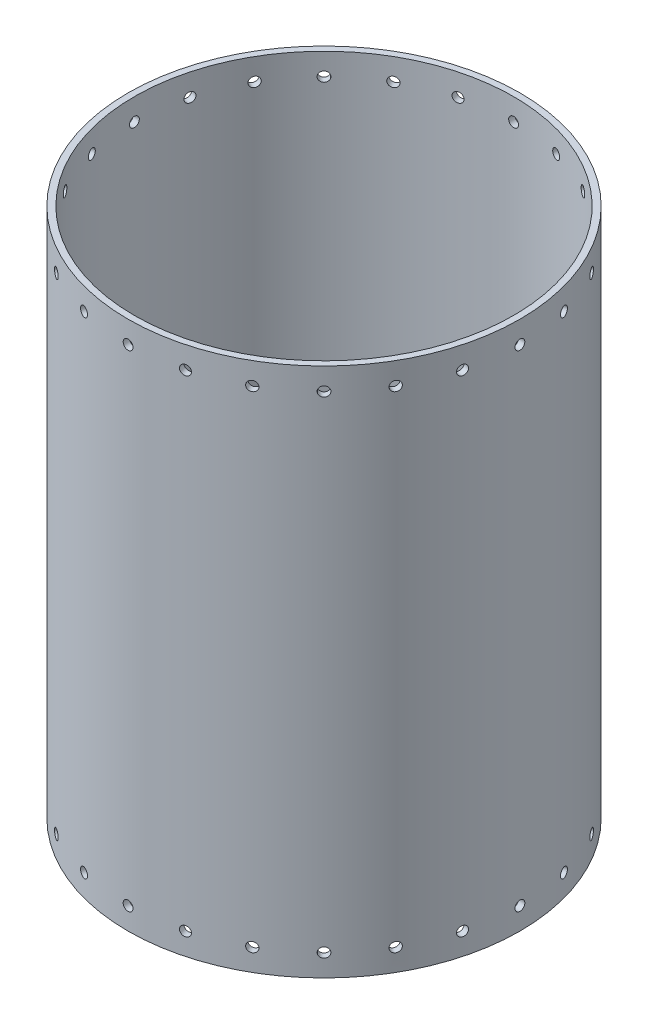
from build123d import *

# Parameters (mm, degrees)
SKETCH1_R                = 101.727
SKETCH1_R_2              = 98.425
EXTRUDE_THIN1_DEPTH      = 275.082
SKETCH2_W                = 2.54
SKETCH2_H                = 12.7
CIRPATTERN1_COUNT        = 24
MIRROR1_COPY_1_SKETCH_W  = 2.54
MIRROR1_COPY_1_SKETCH_H  = 12.7
MIRROR1_COPY_2_SKETCH_W  = 2.54
MIRROR1_COPY_2_SKETCH_H  = 12.7
MIRROR1_COPY_3_SKETCH_W  = 2.54
MIRROR1_COPY_3_SKETCH_H  = 12.7
MIRROR1_COPY_4_SKETCH_W  = 2.54
MIRROR1_COPY_4_SKETCH_H  = 12.7
MIRROR1_COPY_5_SKETCH_W  = 2.54
MIRROR1_COPY_5_SKETCH_H  = 12.7
MIRROR1_COPY_6_SKETCH_W  = 2.54
MIRROR1_COPY_6_SKETCH_H  = 12.7
MIRROR1_COPY_7_SKETCH_W  = 2.54
MIRROR1_COPY_7_SKETCH_H  = 12.7
MIRROR1_COPY_8_SKETCH_W  = 2.54
MIRROR1_COPY_8_SKETCH_H  = 12.7
MIRROR1_COPY_9_SKETCH_W  = 2.54
MIRROR1_COPY_9_SKETCH_H  = 12.7
MIRROR1_COPY_10_SKETCH_W = 2.54
MIRROR1_COPY_10_SKETCH_H = 12.7
MIRROR1_COPY_11_SKETCH_W = 2.54
MIRROR1_COPY_11_SKETCH_H = 12.7
MIRROR1_COPY_12_SKETCH_W = 2.54
MIRROR1_COPY_12_SKETCH_H = 12.7
MIRROR1_COPY_13_SKETCH_W = 2.54
MIRROR1_COPY_13_SKETCH_H = 12.7
MIRROR1_COPY_14_SKETCH_W = 2.54
MIRROR1_COPY_14_SKETCH_H = 12.7
MIRROR1_COPY_15_SKETCH_W = 2.54
MIRROR1_COPY_15_SKETCH_H = 12.7
MIRROR1_COPY_16_SKETCH_W = 2.54
MIRROR1_COPY_16_SKETCH_H = 12.7
MIRROR1_COPY_17_SKETCH_W = 2.54
MIRROR1_COPY_17_SKETCH_H = 12.7
MIRROR1_COPY_18_SKETCH_W = 2.54
MIRROR1_COPY_18_SKETCH_H = 12.7
MIRROR1_COPY_19_SKETCH_W = 2.54
MIRROR1_COPY_19_SKETCH_H = 12.7
MIRROR1_COPY_20_SKETCH_W = 2.54
MIRROR1_COPY_20_SKETCH_H = 12.7
MIRROR1_COPY_21_SKETCH_W = 2.54
MIRROR1_COPY_21_SKETCH_H = 12.7
MIRROR1_COPY_22_SKETCH_W = 2.54
MIRROR1_COPY_22_SKETCH_H = 12.7
MIRROR1_COPY_23_SKETCH_W = 2.54
MIRROR1_COPY_23_SKETCH_H = 12.7


with BuildPart() as part:
    # Sketch1 → Extrude-Thin1 (new body)
    with BuildSketch(Plane(origin=(0, 0, 0), x_dir=(1, 0, 0), z_dir=(0, 1, 0))):
        Circle(SKETCH1_R)
        Circle(SKETCH1_R_2, mode=Mode.SUBTRACT)
    extrude(amount=EXTRUDE_THIN1_DEPTH)

    # Sketch2 → Cut-Revolve1 (revolve, cut)
    with BuildSketch(Plane(origin=(0, 263.652, 0), x_dir=(1, 0, 0), z_dir=(0, 1, 0))):
        with Locations((1.27, -100.33)):
            Rectangle(SKETCH2_W, SKETCH2_H)
    cut_revolve1 = revolve(axis=Axis((0, 263.652, 0), (0, 0, 1)), mode=Mode.SUBTRACT)

    # CirPattern1: Cut-Revolve1 ×24 about axis
    cirpattern1_axis = Axis((0, 0, 0), (0, 1, 0))
    for i in range(1, CIRPATTERN1_COUNT):
        add(cut_revolve1.rotate(cirpattern1_axis, i * 360 / CIRPATTERN1_COUNT), mode=Mode.SUBTRACT)

    # Mirror1: Cut-Revolve1 across plane
    add(cut_revolve1.mirror(Plane.ZX.offset(137.541)), mode=Mode.SUBTRACT)

    # Mirror1 copy 1 sketch → Mirror1 copy 1 (revolve, cut)
    with BuildSketch(Plane(origin=(0, 11.43, 0), x_dir=(0.965925826, 0, -0.258819045), z_dir=(0, -1, 0))):
        with Locations((1.27, 100.33)):
            Rectangle(MIRROR1_COPY_1_SKETCH_W, MIRROR1_COPY_1_SKETCH_H)
    revolve(axis=Axis((0, 11.43, 0), (-0.258819045, 0, -0.965925826)), mode=Mode.SUBTRACT)

    # Mirror1 copy 2 sketch → Mirror1 copy 2 (revolve, cut)
    with BuildSketch(Plane(origin=(0, 11.43, 0), x_dir=(0.866025404, 0, -0.5), z_dir=(0, -1, 0))):
        with Locations((1.27, 100.33)):
            Rectangle(MIRROR1_COPY_2_SKETCH_W, MIRROR1_COPY_2_SKETCH_H)
    revolve(axis=Axis((0, 11.43, 0), (-0.5, 0, -0.866025404)), mode=Mode.SUBTRACT)

    # Mirror1 copy 3 sketch → Mirror1 copy 3 (revolve, cut)
    with BuildSketch(Plane(origin=(0, 11.43, 0), x_dir=(0.707106781, 0, -0.707106781), z_dir=(0, -1, 0))):
        with Locations((1.27, 100.33)):
            Rectangle(MIRROR1_COPY_3_SKETCH_W, MIRROR1_COPY_3_SKETCH_H)
    revolve(axis=Axis((0, 11.43, 0), (-0.707106781, 0, -0.707106781)), mode=Mode.SUBTRACT)

    # Mirror1 copy 4 sketch → Mirror1 copy 4 (revolve, cut)
    with BuildSketch(Plane(origin=(0, 11.43, 0), x_dir=(0.5, 0, -0.866025404), z_dir=(0, -1, 0))):
        with Locations((1.27, 100.33)):
            Rectangle(MIRROR1_COPY_4_SKETCH_W, MIRROR1_COPY_4_SKETCH_H)
    revolve(axis=Axis((0, 11.43, 0), (-0.866025404, 0, -0.5)), mode=Mode.SUBTRACT)

    # Mirror1 copy 5 sketch → Mirror1 copy 5 (revolve, cut)
    with BuildSketch(Plane(origin=(0, 11.43, 0), x_dir=(0.258819045, 0, -0.965925826), z_dir=(0, -1, 0))):
        with Locations((1.27, 100.33)):
            Rectangle(MIRROR1_COPY_5_SKETCH_W, MIRROR1_COPY_5_SKETCH_H)
    revolve(axis=Axis((0, 11.43, 0), (-0.965925826, 0, -0.258819045)), mode=Mode.SUBTRACT)

    # Mirror1 copy 6 sketch → Mirror1 copy 6 (revolve, cut)
    with BuildSketch(Plane(origin=(0, 11.43, 0), x_dir=(0, 0, -1), z_dir=(0, -1, 0))):
        with Locations((1.27, 100.33)):
            Rectangle(MIRROR1_COPY_6_SKETCH_W, MIRROR1_COPY_6_SKETCH_H)
    revolve(axis=Axis((0, 11.43, 0), (-1, 0, 0)), mode=Mode.SUBTRACT)

    # Mirror1 copy 7 sketch → Mirror1 copy 7 (revolve, cut)
    with BuildSketch(Plane(origin=(0, 11.43, 0), x_dir=(-0.258819045, 0, -0.965925826), z_dir=(0, -1, 0))):
        with Locations((1.27, 100.33)):
            Rectangle(MIRROR1_COPY_7_SKETCH_W, MIRROR1_COPY_7_SKETCH_H)
    revolve(axis=Axis((0, 11.43, 0), (-0.965925826, 0, 0.258819045)), mode=Mode.SUBTRACT)

    # Mirror1 copy 8 sketch → Mirror1 copy 8 (revolve, cut)
    with BuildSketch(Plane(origin=(0, 11.43, 0), x_dir=(-0.5, 0, -0.866025404), z_dir=(0, -1, 0))):
        with Locations((1.27, 100.33)):
            Rectangle(MIRROR1_COPY_8_SKETCH_W, MIRROR1_COPY_8_SKETCH_H)
    revolve(axis=Axis((0, 11.43, 0), (-0.866025404, 0, 0.5)), mode=Mode.SUBTRACT)

    # Mirror1 copy 9 sketch → Mirror1 copy 9 (revolve, cut)
    with BuildSketch(Plane(origin=(0, 11.43, 0), x_dir=(-0.707106781, 0, -0.707106781), z_dir=(0, -1, 0))):
        with Locations((1.27, 100.33)):
            Rectangle(MIRROR1_COPY_9_SKETCH_W, MIRROR1_COPY_9_SKETCH_H)
    revolve(axis=Axis((0, 11.43, 0), (-0.707106781, 0, 0.707106781)), mode=Mode.SUBTRACT)

    # Mirror1 copy 10 sketch → Mirror1 copy 10 (revolve, cut)
    with BuildSketch(Plane(origin=(0, 11.43, 0), x_dir=(-0.866025404, 0, -0.5), z_dir=(0, -1, 0))):
        with Locations((1.27, 100.33)):
            Rectangle(MIRROR1_COPY_10_SKETCH_W, MIRROR1_COPY_10_SKETCH_H)
    revolve(axis=Axis((0, 11.43, 0), (-0.5, 0, 0.866025404)), mode=Mode.SUBTRACT)

    # Mirror1 copy 11 sketch → Mirror1 copy 11 (revolve, cut)
    with BuildSketch(Plane(origin=(0, 11.43, 0), x_dir=(-0.965925826, 0, -0.258819045), z_dir=(0, -1, 0))):
        with Locations((1.27, 100.33)):
            Rectangle(MIRROR1_COPY_11_SKETCH_W, MIRROR1_COPY_11_SKETCH_H)
    revolve(axis=Axis((0, 11.43, 0), (-0.258819045, 0, 0.965925826)), mode=Mode.SUBTRACT)

    # Mirror1 copy 12 sketch → Mirror1 copy 12 (revolve, cut)
    with BuildSketch(Plane(origin=(0, 11.43, 0), x_dir=(-1, 0, 0), z_dir=(0, -1, 0))):
        with Locations((1.27, 100.33)):
            Rectangle(MIRROR1_COPY_12_SKETCH_W, MIRROR1_COPY_12_SKETCH_H)
    revolve(axis=Axis((0, 11.43, 0), (0, 0, 1)), mode=Mode.SUBTRACT)

    # Mirror1 copy 13 sketch → Mirror1 copy 13 (revolve, cut)
    with BuildSketch(Plane(origin=(0, 11.43, 0), x_dir=(-0.965925826, 0, 0.258819045), z_dir=(0, -1, 0))):
        with Locations((1.27, 100.33)):
            Rectangle(MIRROR1_COPY_13_SKETCH_W, MIRROR1_COPY_13_SKETCH_H)
    revolve(axis=Axis((0, 11.43, 0), (0.258819045, 0, 0.965925826)), mode=Mode.SUBTRACT)

    # Mirror1 copy 14 sketch → Mirror1 copy 14 (revolve, cut)
    with BuildSketch(Plane(origin=(0, 11.43, 0), x_dir=(-0.866025404, 0, 0.5), z_dir=(0, -1, 0))):
        with Locations((1.27, 100.33)):
            Rectangle(MIRROR1_COPY_14_SKETCH_W, MIRROR1_COPY_14_SKETCH_H)
    revolve(axis=Axis((0, 11.43, 0), (0.5, 0, 0.866025404)), mode=Mode.SUBTRACT)

    # Mirror1 copy 15 sketch → Mirror1 copy 15 (revolve, cut)
    with BuildSketch(Plane(origin=(0, 11.43, 0), x_dir=(-0.707106781, 0, 0.707106781), z_dir=(0, -1, 0))):
        with Locations((1.27, 100.33)):
            Rectangle(MIRROR1_COPY_15_SKETCH_W, MIRROR1_COPY_15_SKETCH_H)
    revolve(axis=Axis((0, 11.43, 0), (0.707106781, 0, 0.707106781)), mode=Mode.SUBTRACT)

    # Mirror1 copy 16 sketch → Mirror1 copy 16 (revolve, cut)
    with BuildSketch(Plane(origin=(0, 11.43, 0), x_dir=(-0.5, 0, 0.866025404), z_dir=(0, -1, 0))):
        with Locations((1.27, 100.33)):
            Rectangle(MIRROR1_COPY_16_SKETCH_W, MIRROR1_COPY_16_SKETCH_H)
    revolve(axis=Axis((0, 11.43, 0), (0.866025404, 0, 0.5)), mode=Mode.SUBTRACT)

    # Mirror1 copy 17 sketch → Mirror1 copy 17 (revolve, cut)
    with BuildSketch(Plane(origin=(0, 11.43, 0), x_dir=(-0.258819045, 0, 0.965925826), z_dir=(0, -1, 0))):
        with Locations((1.27, 100.33)):
            Rectangle(MIRROR1_COPY_17_SKETCH_W, MIRROR1_COPY_17_SKETCH_H)
    revolve(axis=Axis((0, 11.43, 0), (0.965925826, 0, 0.258819045)), mode=Mode.SUBTRACT)

    # Mirror1 copy 18 sketch → Mirror1 copy 18 (revolve, cut)
    with BuildSketch(Plane(origin=(0, 11.43, 0), x_dir=(0, 0, 1), z_dir=(0, -1, 0))):
        with Locations((1.27, 100.33)):
            Rectangle(MIRROR1_COPY_18_SKETCH_W, MIRROR1_COPY_18_SKETCH_H)
    revolve(axis=Axis((0, 11.43, 0), (1, 0, 0)), mode=Mode.SUBTRACT)

    # Mirror1 copy 19 sketch → Mirror1 copy 19 (revolve, cut)
    with BuildSketch(Plane(origin=(0, 11.43, 0), x_dir=(0.258819045, 0, 0.965925826), z_dir=(0, -1, 0))):
        with Locations((1.27, 100.33)):
            Rectangle(MIRROR1_COPY_19_SKETCH_W, MIRROR1_COPY_19_SKETCH_H)
    revolve(axis=Axis((0, 11.43, 0), (0.965925826, 0, -0.258819045)), mode=Mode.SUBTRACT)

    # Mirror1 copy 20 sketch → Mirror1 copy 20 (revolve, cut)
    with BuildSketch(Plane(origin=(0, 11.43, 0), x_dir=(0.5, 0, 0.866025404), z_dir=(0, -1, 0))):
        with Locations((1.27, 100.33)):
            Rectangle(MIRROR1_COPY_20_SKETCH_W, MIRROR1_COPY_20_SKETCH_H)
    revolve(axis=Axis((0, 11.43, 0), (0.866025404, 0, -0.5)), mode=Mode.SUBTRACT)

    # Mirror1 copy 21 sketch → Mirror1 copy 21 (revolve, cut)
    with BuildSketch(Plane(origin=(0, 11.43, 0), x_dir=(0.707106781, 0, 0.707106781), z_dir=(0, -1, 0))):
        with Locations((1.27, 100.33)):
            Rectangle(MIRROR1_COPY_21_SKETCH_W, MIRROR1_COPY_21_SKETCH_H)
    revolve(axis=Axis((0, 11.43, 0), (0.707106781, 0, -0.707106781)), mode=Mode.SUBTRACT)

    # Mirror1 copy 22 sketch → Mirror1 copy 22 (revolve, cut)
    with BuildSketch(Plane(origin=(0, 11.43, 0), x_dir=(0.866025404, 0, 0.5), z_dir=(0, -1, 0))):
        with Locations((1.27, 100.33)):
            Rectangle(MIRROR1_COPY_22_SKETCH_W, MIRROR1_COPY_22_SKETCH_H)
    revolve(axis=Axis((0, 11.43, 0), (0.5, 0, -0.866025404)), mode=Mode.SUBTRACT)

    # Mirror1 copy 23 sketch → Mirror1 copy 23 (revolve, cut)
    with BuildSketch(Plane(origin=(0, 11.43, 0), x_dir=(0.965925826, 0, 0.258819045), z_dir=(0, -1, 0))):
        with Locations((1.27, 100.33)):
            Rectangle(MIRROR1_COPY_23_SKETCH_W, MIRROR1_COPY_23_SKETCH_H)
    revolve(axis=Axis((0, 11.43, 0), (0.258819045, 0, -0.965925826)), mode=Mode.SUBTRACT)


solid = part.part
